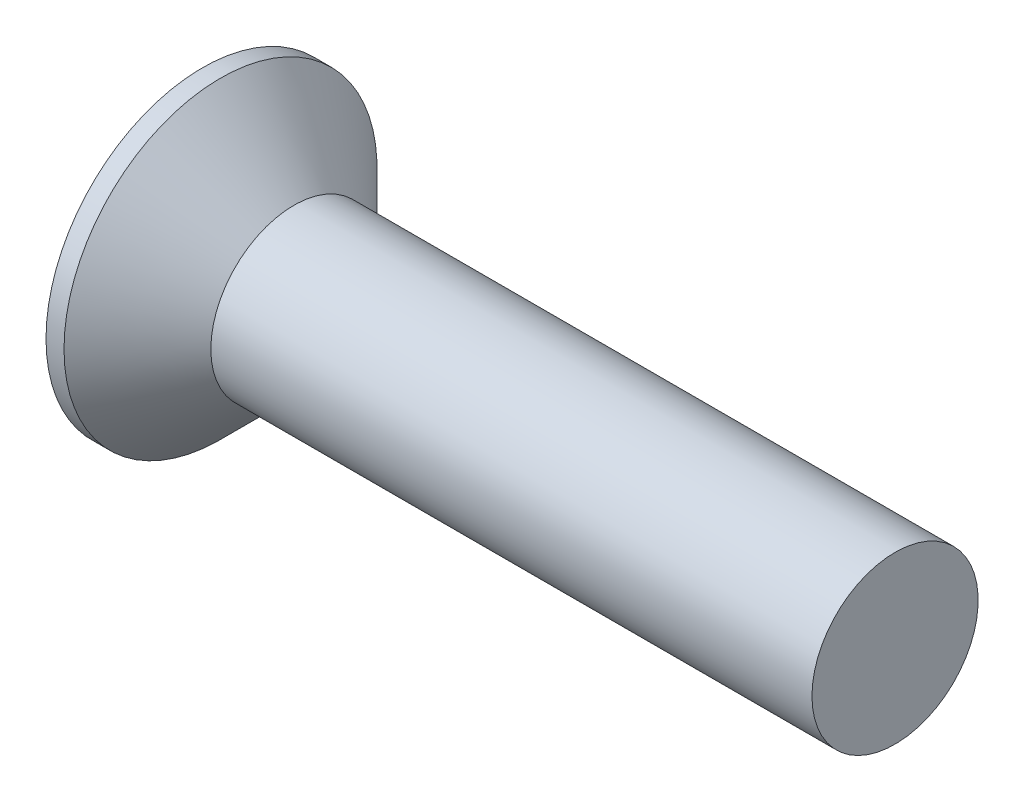
from build123d import *

# Parameters (mm, degrees)
SKETCH3_W         = 1.12
SKETCH3_H         = 6.62
SKETCH4_W         = 0.56
SKETCH4_H         = 0.56
CIRPATTERN1_COUNT = 2
CIRPATTERN1_ANGLE = 90


with BuildPart() as part:
    # BodySke → Base-Revolve (revolve)
    with BuildSketch(Plane.XY):
        Polygon((0, 0), (0, 5.65), (0.65, 5.65), (3.3, 3), (25, 3), (25, 0), align=None)
    revolve(axis=Axis((-6.35, 0, 0), (1, 0, 0)))

    # Sketch3 → Cross section 0
    with BuildSketch(Plane.ZY):
        Rectangle(SKETCH3_W, SKETCH3_H)
    # Sketch4 → Cross section 1
    with BuildSketch(Plane.ZY.offset(-3.61)):
        Rectangle(SKETCH4_W, SKETCH4_H)
    cross = loft(mode=Mode.SUBTRACT)

    # CirPattern1: Cross ×2 about axis
    cirpattern1_axis = Axis((0, 0, 0), (1, 0, 0))
    for i in range(1, CIRPATTERN1_COUNT):
        add(cross.rotate(cirpattern1_axis, i * CIRPATTERN1_ANGLE / (CIRPATTERN1_COUNT - 1)), mode=Mode.SUBTRACT)


solid = part.part
